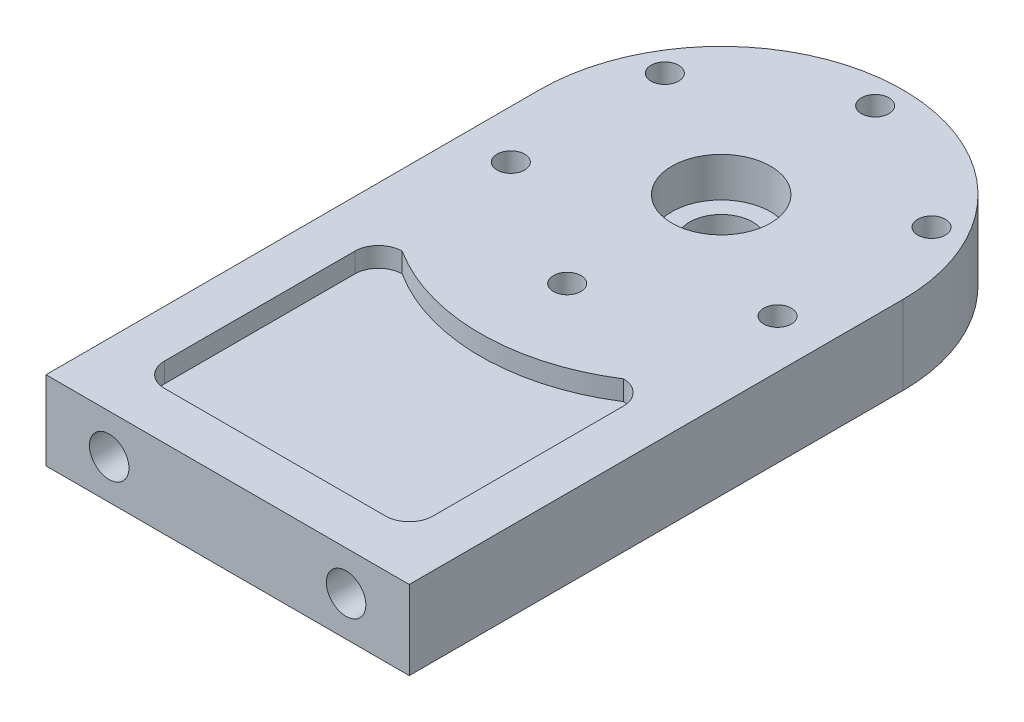
from build123d import *

# Parameters (mm, degrees)
BOSS_EXTRUDE1_DEPTH = 40
SKETCH5_R           = 25
CUT_EXTRUDE1_DEPTH  = 20
SKETCH6_R           = 16
CUT_EXTRUDE2_DEPTH  = 20
SKETCH7_R           = 7
CUT_EXTRUDE3_DEPTH  = 25
CIRPATTERN1_COUNT   = 6
SKETCH8_R           = 12
CUT_EXTRUDE4_DEPTH  = 15
CIRPATTERN2_COUNT   = 6
CUT_EXTRUDE5_DEPTH  = 10
SKETCH13_R          = 10
CUT_EXTRUDE10_DEPTH = 20


with BuildPart() as part:
    # Sketch3 → Boss-Extrude1 (new body)
    with BuildSketch(Plane(origin=(0, 0, 0), x_dir=(1, 0, 0), z_dir=(0, 1, 0))):
        with BuildLine():
            Line((0, 0), (184, 0))
            Line((184, 0), (184, 250))
            ThreePointArc((184, 250), (92, 342), (0, 250))
            Line((0, 250), (0, 0))
        make_face()
    extrude(amount=BOSS_EXTRUDE1_DEPTH)

    # Sketch5 → Cut-Extrude1 (cut)
    with BuildSketch(Plane(origin=(0, 40, 0), x_dir=(1, 0, 0), z_dir=(0, 1, 0))):
        with Locations((92, 250)):
            Circle(SKETCH5_R)
    extrude(amount=-CUT_EXTRUDE1_DEPTH, mode=Mode.SUBTRACT)

    # Sketch6 → Cut-Extrude2 (cut)
    with BuildSketch(Plane.XZ):
        with Locations((92, -250)):
            Circle(SKETCH6_R)
    extrude(amount=-CUT_EXTRUDE2_DEPTH, mode=Mode.SUBTRACT)

    # Sketch7 → Cut-Extrude3 (cut)
    with BuildSketch(Plane(origin=(0, 40, 0), x_dir=(1, 0, 0), z_dir=(0, 1, 0))):
        with Locations((92, 328)):
            Circle(SKETCH7_R)
    cut_extrude3 = extrude(amount=-CUT_EXTRUDE3_DEPTH, mode=Mode.SUBTRACT)

    # CirPattern1: Cut-Extrude3 ×6 about axis
    cirpattern1_axis = Axis((92, 0, -250), (0, 1, 0))
    for i in range(1, CIRPATTERN1_COUNT):
        add(cut_extrude3.rotate(cirpattern1_axis, i * 360 / CIRPATTERN1_COUNT), mode=Mode.SUBTRACT)

    # Sketch8 → Cut-Extrude4 (cut)
    with BuildSketch(Plane.XZ):
        with Locations((92, -328)):
            Circle(SKETCH8_R)
    cut_extrude4 = extrude(amount=-CUT_EXTRUDE4_DEPTH, mode=Mode.SUBTRACT)

    # CirPattern2: Cut-Extrude4 ×6 about axis
    cirpattern2_axis = Axis((92, 0, -250), (0, 1, 0))
    for i in range(1, CIRPATTERN2_COUNT):
        add(cut_extrude4.rotate(cirpattern2_axis, i * 360 / CIRPATTERN2_COUNT), mode=Mode.SUBTRACT)

    # Sketch9 → Cut-Extrude5 (cut)
    with BuildSketch(Plane(origin=(0, 40, 0), x_dir=(1, 0, 0), z_dir=(0, 1, 0))):
        with BuildLine():
            Line((36, 24), (148, 24))
            ThreePointArc((148, 24), (156.485281374, 27.514718626), (160, 36))
            Line((160, 36), (160, 132.420765027))
            ThreePointArc((160, 132.420765027), (156.485281374, 140.906046402), (148, 144.420765027))
            ThreePointArc((148, 144.420765027), (92, 128.056374228), (36, 144.420765027))
            ThreePointArc((36, 144.420765027), (27.514718626, 140.906046402), (24, 132.420765027))
            Line((24, 132.420765027), (24, 36))
            ThreePointArc((24, 36), (27.514718626, 27.514718626), (36, 24))
        make_face()
    cut_extrude5 = extrude(amount=-CUT_EXTRUDE5_DEPTH, mode=Mode.SUBTRACT)

    # Mirror1: Cut-Extrude5 across plane
    add(cut_extrude5.mirror(Plane.ZX.offset(20)), mode=Mode.SUBTRACT)

    # Sketch13 → Cut-Extrude10 (cut)
    with BuildSketch(Plane.XY):
        with Locations((32, 20)):
            Circle(SKETCH13_R)
        with Locations((152, 20)):
            Circle(SKETCH13_R)
    extrude(amount=-CUT_EXTRUDE10_DEPTH, mode=Mode.SUBTRACT)


solid = part.part
